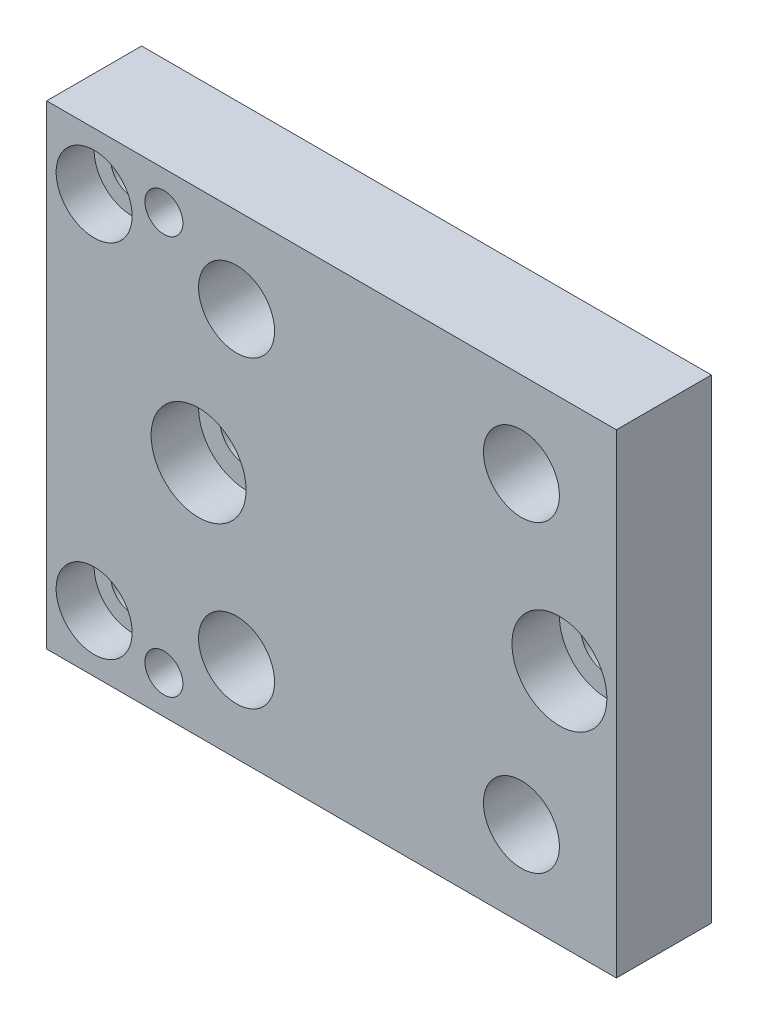
from build123d import *

# Parameters (mm, degrees)
SKETCH1_W           = 60
SKETCH1_H           = 50
SKETCH1_R           = 4
SKETCH1_R_2         = 2.25
SKETCH1_R_3         = 2.75
SKETCH1_R_4         = 2
BOSS_EXTRUDE2_DEPTH = 10
SKETCH2_R           = 4
CUT_EXTRUDE1_DEPTH  = 4
SKETCH3_R           = 5
CUT_EXTRUDE2_DEPTH  = 5


with BuildPart() as part:
    # Sketch1 → Boss-Extrude2 (new body)
    with BuildSketch(Plane.XY):
        with Locations((-30, 25)):
            Rectangle(SKETCH1_W, SKETCH1_H)
        with Locations((-10, 41)):
            Circle(SKETCH1_R, mode=Mode.SUBTRACT)
        with Locations((-10, 9)):
            Circle(SKETCH1_R, mode=Mode.SUBTRACT)
        with Locations((-40, 9)):
            Circle(SKETCH1_R, mode=Mode.SUBTRACT)
        with Locations((-40, 41)):
            Circle(SKETCH1_R, mode=Mode.SUBTRACT)
        with Locations((-55, 44)):
            Circle(SKETCH1_R_2, mode=Mode.SUBTRACT)
        with Locations((-55, 6)):
            Circle(SKETCH1_R_2, mode=Mode.SUBTRACT)
        with Locations((-44, 25)):
            Circle(SKETCH1_R_3, mode=Mode.SUBTRACT)
        with Locations((-6, 25)):
            Circle(SKETCH1_R_3, mode=Mode.SUBTRACT)
        with Locations((-47.652499067, 46)):
            Circle(SKETCH1_R_4, mode=Mode.SUBTRACT)
        with Locations((-47.652499067, 4)):
            Circle(SKETCH1_R_4, mode=Mode.SUBTRACT)
    extrude(amount=BOSS_EXTRUDE2_DEPTH)

    # Sketch2 → Cut-Extrude1 (cut)
    with BuildSketch(Plane.XY.offset(10)):
        with Locations((-55, 44)):
            Circle(SKETCH2_R)
        with Locations((-55, 6)):
            Circle(SKETCH2_R)
    extrude(amount=-CUT_EXTRUDE1_DEPTH, mode=Mode.SUBTRACT)

    # Sketch3 → Cut-Extrude2 (cut)
    with BuildSketch(Plane.XY.offset(10)):
        with Locations((-44, 25)):
            Circle(SKETCH3_R)
        with Locations((-6, 25)):
            Circle(SKETCH3_R)
    extrude(amount=-CUT_EXTRUDE2_DEPTH, mode=Mode.SUBTRACT)


solid = part.part
